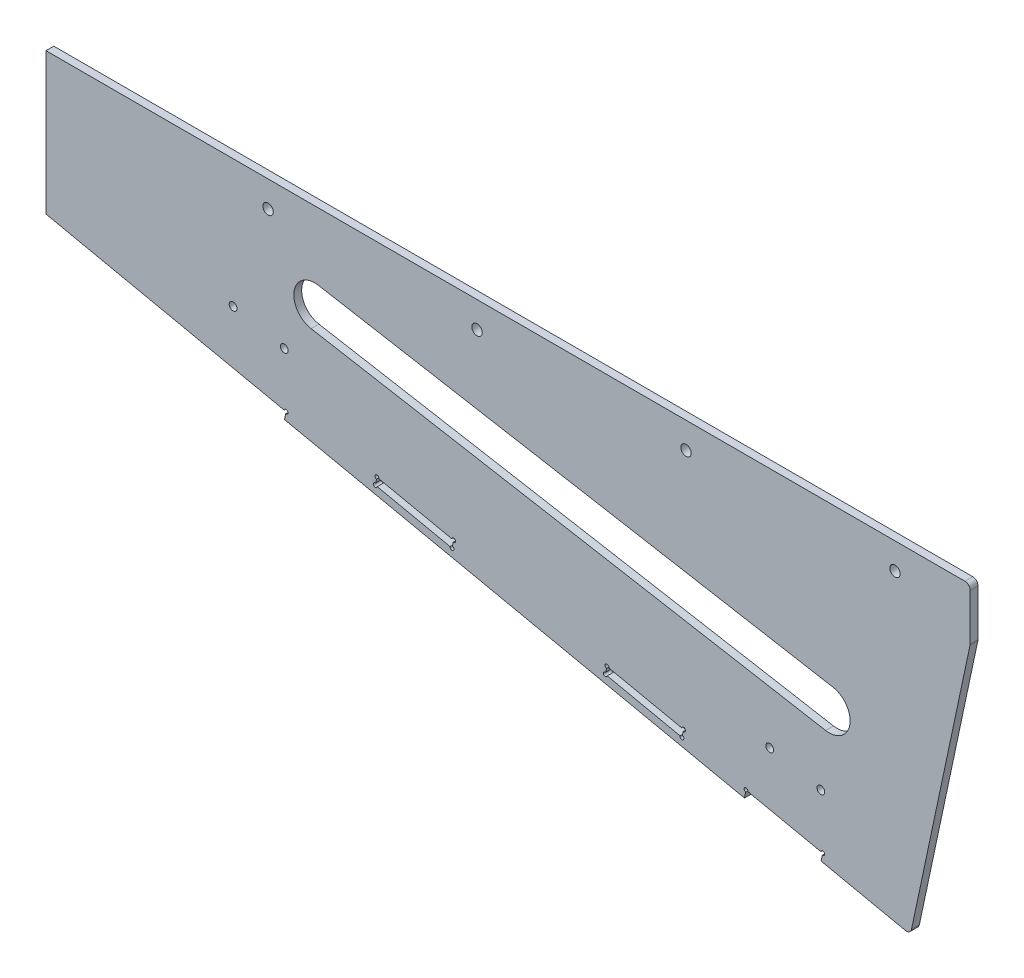
from build123d import *

# Parameters (mm, degrees)
EXTRUDE_1_DEPTH      = 3
CUT_EXTRUDE_2_DEPTH  = 10
CUT_EXTRUDE_6_DEPTH  = 4
SKETCH_12_W          = 293.771267283
SKETCH_12_H          = 20
EXTRUDE_2_DEPTH      = 3
SKETCH_13_R          = 2
CUT_EXTRUDE_9_DEPTH  = 4
CUT_EXTRUDE_10_DEPTH = 10
MM_2_D               = 1.5
CUT_EXTRUDE_11_DEPTH = 4
MM_3_D               = 1.5
FILLET_1_R           = 2
EXTRUDE_3_DEPTH      = 3
SKETCH_4_R           = 1.5
CUT_EXTRUDE_3_DEPTH  = 10


with BuildPart() as part:
    # 草图1 → 凸台-拉伸1 (new body)
    with BuildSketch(Plane.XY):
        Polygon((-31.770103996, 71.767703031), (318.229896004, 71.767703031), (292.931935015, -47.249845949), (-31.770103996, 21.767703031), align=None)
    extrude(amount=EXTRUDE_1_DEPTH)

    # 草图3 → 切除-拉伸2 (cut)
    with BuildSketch(Plane.XY.offset(3)):
        Polygon((-0.469380772, 15.114528924), (0.1543543, 18.048971727), (-31.770103996, 24.834724815), (-31.770103996, 21.767703031), align=None)
        Polygon((176.220922432, -19.375132621), (205.565350454, -25.612483345), (204.941615382, -28.546926147), (175.59718736, -22.309575423), align=None)
    extrude(amount=-CUT_EXTRUDE_2_DEPTH, mode=Mode.SUBTRACT)

    # 草图7 → 切除-拉伸6 (cut, through all)
    with BuildSketch(Plane.XY.offset(3)):
        Polygon((292.931935015, -47.249845949), (239.133816975, -35.814702954), (262.001163287, 71.767703031), (318.229896004, 71.767703031), align=None)
    extrude(amount=-CUT_EXTRUDE_6_DEPTH, mode=Mode.SUBTRACT)

    # 草图12 → 凸台-拉伸2 (add)
    with BuildSketch(Plane.XY.offset(3)):
        with Locations((115.115529646, 81.767703031)):
            Rectangle(SKETCH_12_W, SKETCH_12_H)
    extrude(amount=-EXTRUDE_2_DEPTH)

    # 草图13 → 切除-拉伸9 (cut, through all)
    with BuildSketch(Plane.XY.offset(3)):
        with Locations((-6.770103996, 81.767703031)):
            Circle(SKETCH_13_R)
        with Locations((73.229896004, 81.767703031)):
            Circle(SKETCH_13_R)
        with Locations((153.229896004, 81.767703031)):
            Circle(SKETCH_13_R)
        with Locations((233.229896004, 81.767703031)):
            Circle(SKETCH_13_R)
    extrude(amount=-CUT_EXTRUDE_9_DEPTH, mode=Mode.SUBTRACT)

    # 草图14 → 切除-拉伸10 (cut)
    with BuildSketch(Plane.XY.offset(3)):
        with BuildLine():
            Line((12.482478027, 66.115949401), (209.444028629, 31.386313867))
            ThreePointArc((209.444028629, 31.386313867), (215.933305232, 22.118666422), (206.665657786, 15.629389819))
            Line((206.665657786, 15.629389819), (9.704107184, 50.359025353))
            ThreePointArc((9.704107184, 50.359025353), (3.214830581, 59.626672798), (12.482478027, 66.115949401))
        make_face()
    extrude(amount=-CUT_EXTRUDE_10_DEPTH, mode=Mode.SUBTRACT)

    # 大小mm 暗销槽口2 (through all)
    with Locations(Plane.XY.offset(3)):
        with Locations((0.1543543, 18.048971727), (176.220922432, -19.375132621), (205.565350454, -25.612483345)):
            Hole(MM_2_D / 2)

    # 草图18 → 切除-拉伸11 (cut, through all)
    with BuildSketch(Plane(origin=(0, 0, 0), x_dir=(-1, 0, 0), z_dir=(0, 0, -1))):
        Polygon((-152.291642964, -11.221785469), (-151.667907892, -14.156228271), (-122.32347987, -7.918877547), (-122.947214942, -4.984434744), align=None)
        Polygon((-64.258358898, 7.490266705), (-63.634623826, 4.555823902), (-34.290195804, 10.793174627), (-34.913930876, 13.727617429), align=None)
    extrude(amount=-CUT_EXTRUDE_11_DEPTH, mode=Mode.SUBTRACT)

    # 大小mm 暗销槽口3 (through all)
    with Locations(Plane(origin=(0, 0, 0), x_dir=(-1, 0, 0), z_dir=(0, 0, -1))):
        with Locations((-152.291642964, -11.221785469), (-151.667907892, -14.156228271), (-122.32347987, -7.918877547), (-122.947214942, -4.984434744), (-64.258358898, 7.490266705), (-63.634623826, 4.555823902), (-34.290195804, 10.793174627), (-34.913930876, 13.727617429)):
            Hole(MM_3_D / 2)

    # 圆角1
    fillet_1_edges = [part.edges().sort_by_distance(p)[0] for p in [
        (-31.770103996, 24.834724815, 1.5),
        (239.133816975, -35.814702954, 1.5),
        (262.001163287, 71.767703031, 1.5),
        (-31.770103996, 91.767703031, 1.5),
        (262.001163287, 91.767703031, 1.5),
    ]]
    fillet(fillet_1_edges, radius=FILLET_1_R)

    # 草图21 → 凸台-拉伸3 (add)
    with BuildSketch(Plane.XY.offset(3)):
        Polygon((-91.770103996, 37.588118515), (-13.862424826, 21.028330103), (-13.862424826, 91.767703031), (-81.382896655, 91.767703031), (-91.770103996, 91.767703031), align=None)
    extrude(amount=-EXTRUDE_3_DEPTH)

    # 草图4 → 切除-拉伸3 (cut)
    with BuildSketch(Plane.XY.offset(3)):
        with Locations((-20.141101902, 42.809716012)):
            Circle(SKETCH_4_R)
        with Locations((-0.578149887, 38.651482195)):
            Circle(SKETCH_4_R)
        with Locations((185.269894252, -0.85173906)):
            Circle(SKETCH_4_R)
        with Locations((204.832846267, -5.009972876)):
            Circle(SKETCH_4_R)
    extrude(amount=-CUT_EXTRUDE_3_DEPTH, mode=Mode.SUBTRACT)


solid = part.part
